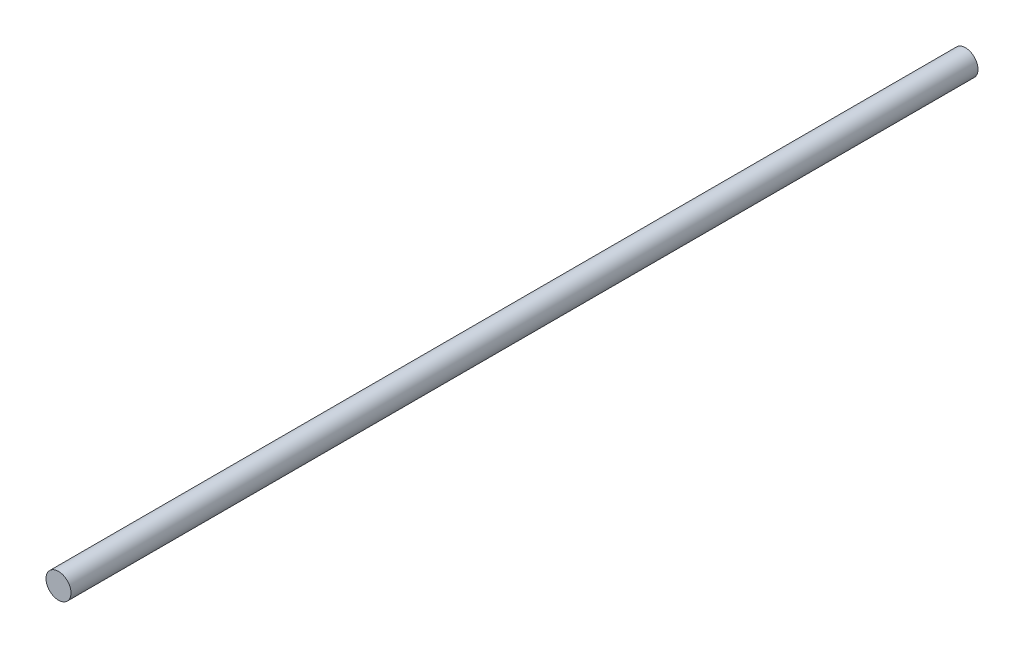
from build123d import *

# Parameters (mm, degrees)
SKETCH1_R           = 4
BOSS_EXTRUDE1_DEPTH = 290


with BuildPart() as part:
    # Sketch1 → Boss-Extrude1 (new body)
    with BuildSketch(Plane.XY):
        with Locations((-32.400371914, 2.118779079)):
            Circle(SKETCH1_R)
    extrude(amount=BOSS_EXTRUDE1_DEPTH)


solid = part.part
